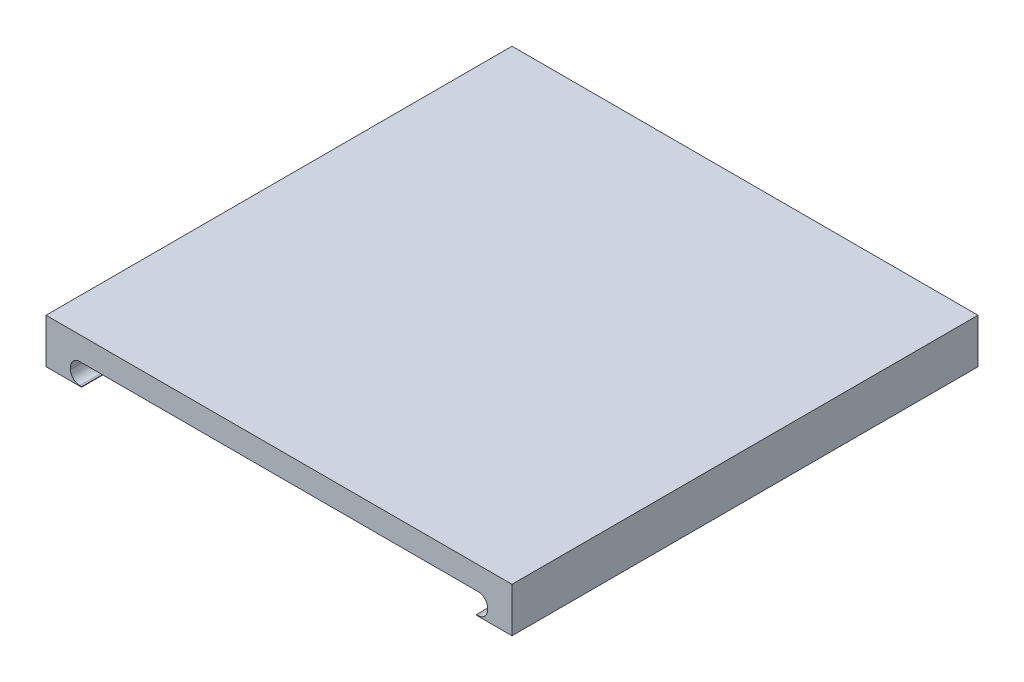
from build123d import *

# Parameters (mm, degrees)
SKETCH2_W           = 50
SKETCH2_H           = 50
BOSS_EXTRUDE1_DEPTH = 5
SKETCH6_W           = 42.36475395
SKETCH6_H           = 2.5
CUT_EXTRUDE1_DEPTH  = 50
SKETCH9_W           = 1.188642814
SKETCH9_H           = 2.221510963
CUT_EXTRUDE3_DEPTH  = 50
FILLET2_R           = 1
FILLET3_R           = 1
SKETCH11_W          = 1.18864281
SKETCH11_H          = 2.22151096
CUT_EXTRUDE4_DEPTH  = 50
FILLET5_R           = 1
FILLET6_R           = 1
SKETCH14_W          = 3.817623025
SKETCH14_H          = 0.21818248
CUT_EXTRUDE5_DEPTH  = 50
SKETCH16_W          = 3.817623025
SKETCH16_H          = 0.211754728
CUT_EXTRUDE6_DEPTH  = 50


with BuildPart() as part:
    # Sketch2 → Boss-Extrude1 (new body)
    with BuildSketch(Plane(origin=(0, 0, 0), x_dir=(1, 0, 0), z_dir=(0, 1, 0))):
        Rectangle(SKETCH2_W, SKETCH2_H)
    extrude(amount=BOSS_EXTRUDE1_DEPTH)

    # Sketch6 → Cut-Extrude1 (cut)
    with BuildSketch(Plane(origin=(0, 0, -25), x_dir=(-1, 0, 0), z_dir=(0, 0, -1))):
        with Locations((0, 1.25)):
            Rectangle(SKETCH6_W, SKETCH6_H)
    extrude(amount=-CUT_EXTRUDE1_DEPTH, mode=Mode.SUBTRACT)

    # Sketch9 → Cut-Extrude3 (cut)
    with BuildSketch(Plane(origin=(0, 0, -25), x_dir=(-1, 0, 0), z_dir=(0, 0, -1))):
        with Locations((-21.776698382, 1.389244518)):
            Rectangle(SKETCH9_W, SKETCH9_H)
    extrude(amount=-CUT_EXTRUDE3_DEPTH, mode=Mode.SUBTRACT)

    # Fillet2
    fillet2_edges = [part.edges().sort_by_distance(p)[0] for p in [
        (22.371019789, 2.5, 0),
    ]]
    fillet(fillet2_edges, radius=FILLET2_R)

    # Fillet3
    fillet3_edges = [part.edges().sort_by_distance(p)[0] for p in [
        (22.371019789, 0.278489037, 0),
    ]]
    fillet(fillet3_edges, radius=FILLET3_R)

    # Sketch11 → Cut-Extrude4 (cut)
    with BuildSketch(Plane.XY.offset(25)):
        with Locations((-21.77669838, 1.38924452)):
            Rectangle(SKETCH11_W, SKETCH11_H)
    extrude(amount=-CUT_EXTRUDE4_DEPTH, mode=Mode.SUBTRACT)

    # Fillet5
    fillet5_edges = [part.edges().sort_by_distance(p)[0] for p in [
        (-22.371019785, 2.5, 0),
    ]]
    fillet(fillet5_edges, radius=FILLET5_R)

    # Fillet6
    fillet6_edges = [part.edges().sort_by_distance(p)[0] for p in [
        (-22.371019785, 0.27848904, 0),
    ]]
    fillet(fillet6_edges, radius=FILLET6_R)

    # Sketch14 → Cut-Extrude5 (cut)
    with BuildSketch(Plane.XY.offset(25)):
        with Locations((-23.091188487, 0.10909124)):
            Rectangle(SKETCH14_W, SKETCH14_H)
    extrude(amount=-CUT_EXTRUDE5_DEPTH, mode=Mode.SUBTRACT)

    # Sketch16 → Cut-Extrude6 (cut)
    with BuildSketch(Plane.XY.offset(25)):
        with Locations((23.091188487, 0.105877364)):
            Rectangle(SKETCH16_W, SKETCH16_H)
    extrude(amount=-CUT_EXTRUDE6_DEPTH, mode=Mode.SUBTRACT)


solid = part.part
